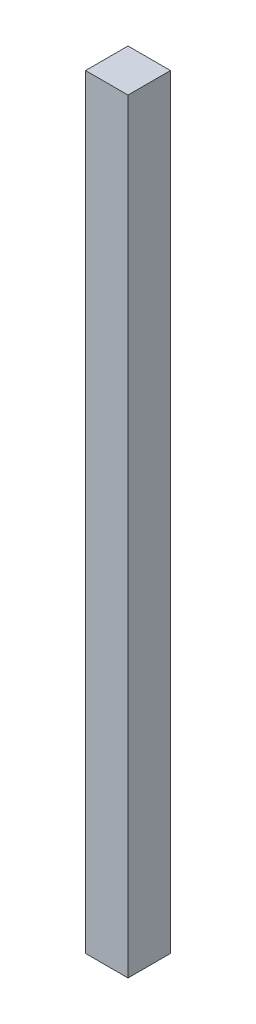
from build123d import *

# Parameters (mm, degrees)
SKETCH1_W           = 25.4
SKETCH1_H           = 25.4
BOSS_EXTRUDE1_DEPTH = 457.2


with BuildPart() as part:
    # Sketch1 → Boss-Extrude1 (new body)
    with BuildSketch(Plane(origin=(0, 0, 0), x_dir=(1, 0, 0), z_dir=(0, 1, 0))):
        with Locations((12.7, 12.7)):
            Rectangle(SKETCH1_W, SKETCH1_H)
    extrude(amount=-BOSS_EXTRUDE1_DEPTH)


solid = part.part
